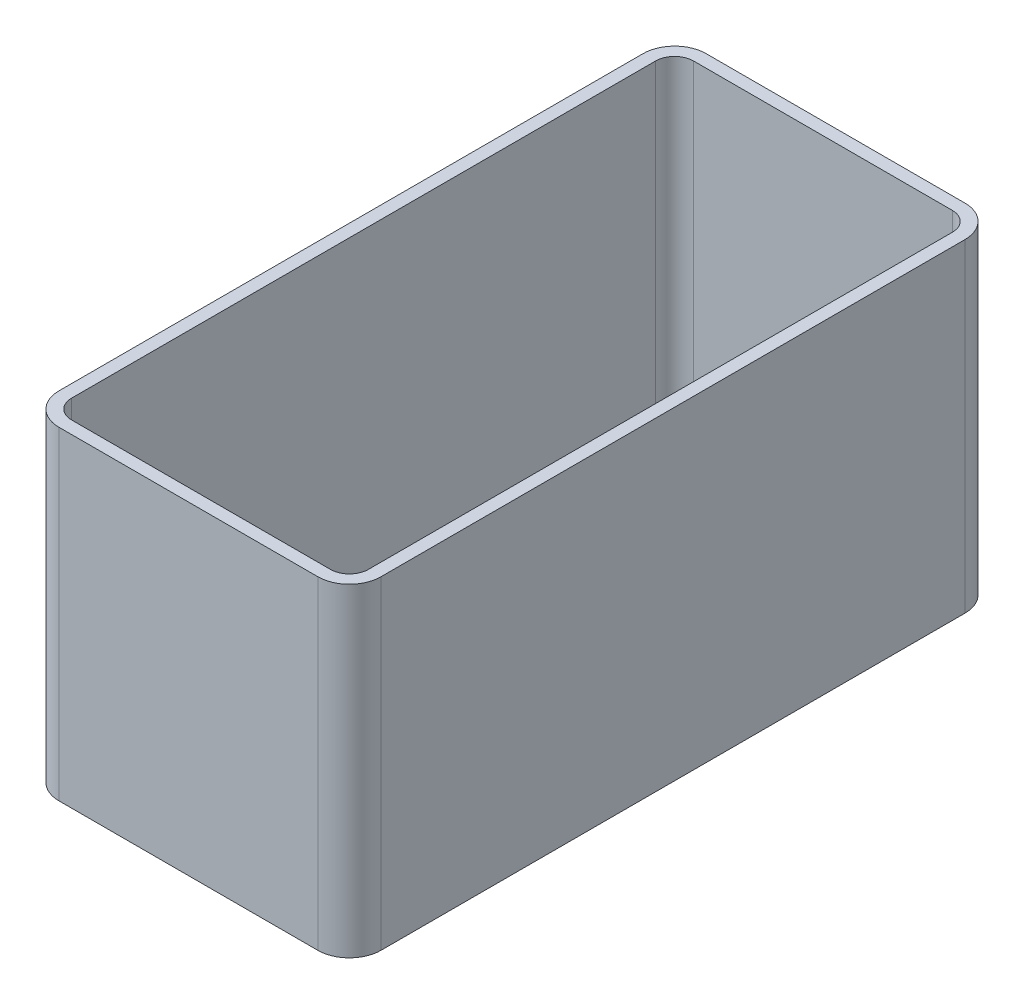
from build123d import *

# Parameters (mm, degrees)
BASES_W            = 20.4
BASES_H            = 41
BASE_DEPTH         = 10.25
BASE_F_R           = 2
CUT_EXTRUDE3_DEPTH = 21.5


with BuildPart() as part:
    # BaseS → BASE (new body, symmetric)
    with BuildSketch(Plane(origin=(0, 0, 0), x_dir=(1, 0, 0), z_dir=(0, 1, 0))):
        Rectangle(BASES_W, BASES_H)
    extrude(amount=BASE_DEPTH, both=True)

    # BASE F
    base_f_edges = [part.edges().sort_by_distance(p)[0] for p in [
        (10.2, 0, 20.5),
        (-10.2, 0, 20.5),
        (-10.2, 0, -20.5),
        (10.2, 0, -20.5),
    ]]
    fillet(base_f_edges, radius=BASE_F_R)

    # PocketS → Cut-Extrude3 (cut, through all)
    with BuildSketch(Plane(origin=(0, 10.25, 0), x_dir=(1, 0, 0), z_dir=(0, 1, 0))):
        with BuildLine():
            Line((8.2, 19.7), (-8.2, 19.7))
            ThreePointArc((-8.2, 19.7), (-9.048528137, 19.348528137), (-9.4, 18.5))
            Line((-9.4, 18.5), (-9.4, -18.5))
            ThreePointArc((-9.4, -18.5), (-9.048528137, -19.348528137), (-8.2, -19.7))
            Line((-8.2, -19.7), (8.2, -19.7))
            ThreePointArc((8.2, -19.7), (9.048528137, -19.348528137), (9.4, -18.5))
            Line((9.4, -18.5), (9.4, 18.5))
            ThreePointArc((9.4, 18.5), (9.048528137, 19.348528137), (8.2, 19.7))
        make_face()
    extrude(amount=-CUT_EXTRUDE3_DEPTH, mode=Mode.SUBTRACT)


solid = part.part
